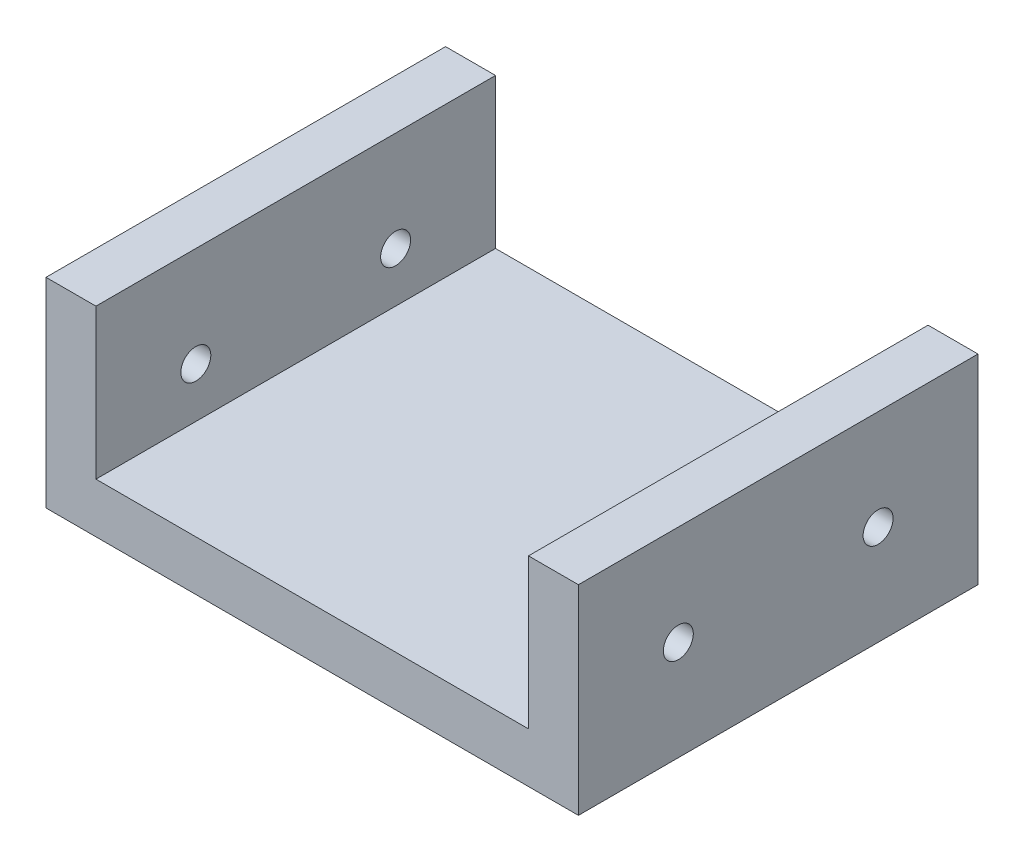
from build123d import *

# Parameters (mm, degrees)
ESQUISSE1_W             = 53.3
ESQUISSE1_H             = 40
BOSS_EXTRU_1_DEPTH      = 20
ESQUISSE2_W             = 43.3
ESQUISSE2_H             = 40
ENL_V_MAT_EXTRU_1_DEPTH = 15
ESQUISSE3_R             = 1.5
ENL_V_MAT_EXTRU_2_DEPTH = 54.3


with BuildPart() as part:
    # Esquisse1 → Boss.-Extru.1 (new body)
    with BuildSketch(Plane(origin=(0, 0, 0), x_dir=(1, 0, 0), z_dir=(0, 1, 0))):
        with Locations((26.65, -20)):
            Rectangle(ESQUISSE1_W, ESQUISSE1_H)
    extrude(amount=BOSS_EXTRU_1_DEPTH)

    # Esquisse2 → Enlèv. mat.-Extru.1 (cut)
    with BuildSketch(Plane(origin=(0, 20, 0), x_dir=(1, 0, 0), z_dir=(0, 1, 0))):
        with Locations((26.65, -20)):
            Rectangle(ESQUISSE2_W, ESQUISSE2_H)
    extrude(amount=-ENL_V_MAT_EXTRU_1_DEPTH, mode=Mode.SUBTRACT)

    # Esquisse3 → Enlèv. mat.-Extru.2 (cut, through all)
    with BuildSketch(Plane(origin=(53.3, 0, 0), x_dir=(0, 0, -1), z_dir=(1, 0, 0))):
        with Locations((-30, 10)):
            Circle(ESQUISSE3_R)
        with Locations((-10, 10)):
            Circle(ESQUISSE3_R)
    extrude(amount=-ENL_V_MAT_EXTRU_2_DEPTH, mode=Mode.SUBTRACT)


solid = part.part
